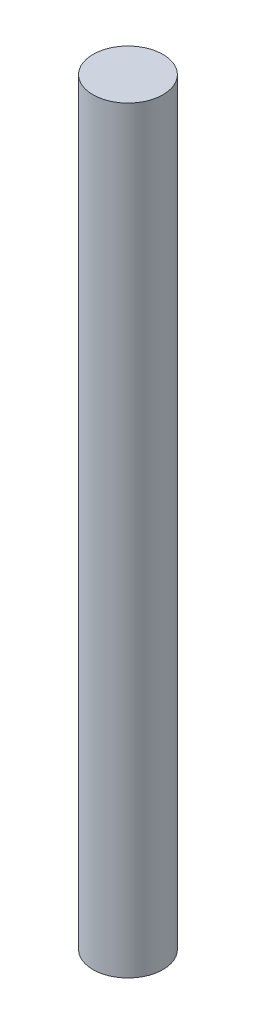
from build123d import *

# Parameters (mm, degrees)
SKETCH5_R           = 3
BOSS_EXTRUDE3_DEPTH = 65


with BuildPart() as part:
    # Sketch5 → Boss-Extrude3 (new body)
    with BuildSketch(Plane(origin=(0, 0, 0), x_dir=(1, 0, 0), z_dir=(0, 1, 0))):
        Circle(SKETCH5_R)
    extrude(amount=BOSS_EXTRUDE3_DEPTH)


solid = part.part
